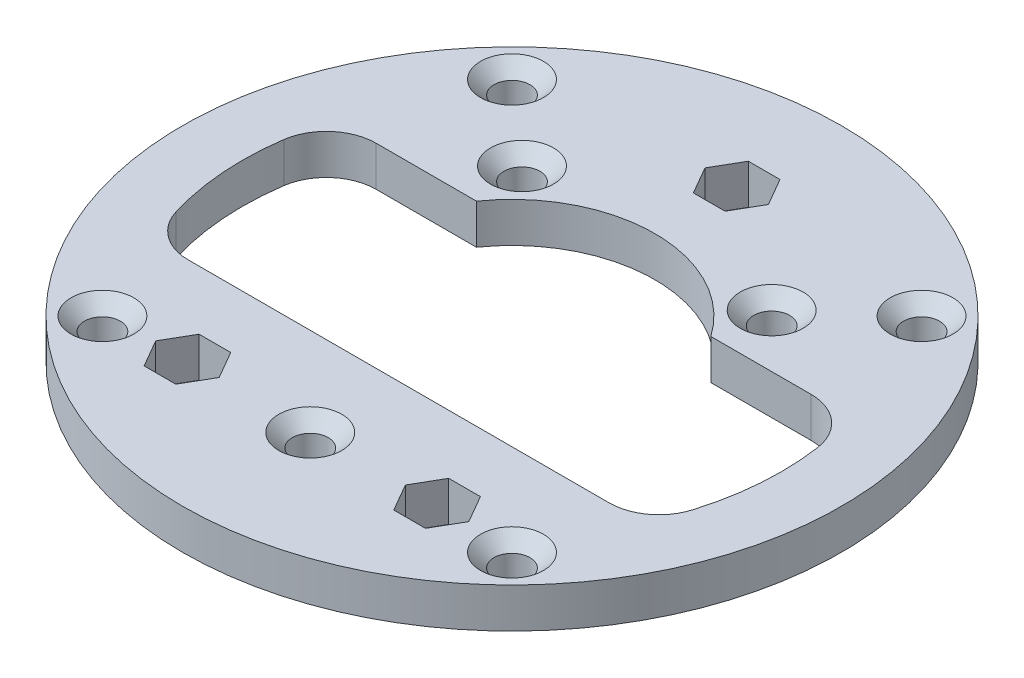
from build123d import *

# Parameters (mm, degrees)
SKETCH1_R                                       = 33
SKETCH1_R_2                                     = 27
BOSS_EXTRUDE1_DEPTH                             = 4
SKETCH2_R                                       = 1.5
SALIENTE_EXTRUIR1_DEPTH                         = 4
CORTAR_EXTRUIR1_REACH                           = 6
CROQUIS1_R                                      = 1.75
CSK_FOR_M3_FLAT_HEAD_MACHINE_SCREW1_D           = 3.6
CSK_FOR_M3_FLAT_HEAD_MACHINE_SCREW1_CSINK_D     = 6.3
CSK_FOR_M3_FLAT_HEAD_MACHINE_SCREW1_CSINK_ANGLE = 90
CSK_FOR_M3_FLAT_HEAD_MACHINE_SCREW2_D           = 3.6
CSK_FOR_M3_FLAT_HEAD_MACHINE_SCREW2_CSINK_D     = 6.3
CSK_FOR_M3_FLAT_HEAD_MACHINE_SCREW2_CSINK_ANGLE = 90
FILLET1_R                                       = 5


with BuildPart() as part:
    # Sketch1 → Boss-Extrude1 (new body)
    with BuildSketch(Plane(origin=(0, 0, 0), x_dir=(1, 0, 0), z_dir=(0, 1, 0))):
        Circle(SKETCH1_R)
        Circle(SKETCH1_R_2, mode=Mode.SUBTRACT)
    extrude(amount=BOSS_EXTRUDE1_DEPTH)

    # Sketch2 → Saliente-Extruir1 (add)
    with BuildSketch(Plane(origin=(0, 4, 0), x_dir=(1, 0, 0), z_dir=(0, 1, 0))):
        with BuildLine():
            Line((-24.5, -11.346805718), (24.5, -11.346805718))
            ThreePointArc((24.5, -11.346805718), (0, -27), (-24.5, -11.346805718))
        make_face()
        with Locations((0, -20.2)):
            Circle(SKETCH2_R, mode=Mode.SUBTRACT)
        with BuildLine():
            Line((-25.7325, 8.175478197), (-11.7325, 8.175478197))
            ThreePointArc((-11.7325, 8.175478197), (0, 14.3), (11.7325, 8.175478197))
            Line((11.7325, 8.175478197), (25.7325, 8.175478197))
            ThreePointArc((25.7325, 8.175478197), (0, 27), (-25.7325, 8.175478197))
        make_face()
        with Locations((-12.5, 13.5)):
            Circle(SKETCH2_R, mode=Mode.SUBTRACT)
        with Locations((12.5, 13.5)):
            Circle(SKETCH2_R, mode=Mode.SUBTRACT)
    extrude(amount=-SALIENTE_EXTRUIR1_DEPTH)

    # Croquis1 → Cortar-Extruir1 (cut, up to next)
    with BuildSketch(Plane(origin=(0, 4, 0), x_dir=(1, 0, 0), z_dir=(0, 1, 0)), mode=Mode.PRIVATE) as cortar_extruir1_sk1:
        with Locations((-20.506096654, 20.506096654)):
            Circle(CROQUIS1_R)
    cortar_extruir1_tool1 = extrude(cortar_extruir1_sk1.sketch, amount=-CORTAR_EXTRUIR1_REACH, mode=Mode.PRIVATE) & part.part
    add(cortar_extruir1_tool1.solids().sort_by_distance((-20.506097, 4, -20.506097))[0], mode=Mode.SUBTRACT)
    # Croquis1 → Cortar-Extruir1 (cut, up to next)
    with BuildSketch(Plane(origin=(0, 4, 0), x_dir=(1, 0, 0), z_dir=(0, 1, 0)), mode=Mode.PRIVATE) as cortar_extruir1_sk2:
        with Locations((20.506096654, 20.506096654)):
            Circle(CROQUIS1_R)
    cortar_extruir1_tool2 = extrude(cortar_extruir1_sk2.sketch, amount=-CORTAR_EXTRUIR1_REACH, mode=Mode.PRIVATE) & part.part
    add(cortar_extruir1_tool2.solids().sort_by_distance((20.506097, 4, -20.506097))[0], mode=Mode.SUBTRACT)
    # Croquis1 → Cortar-Extruir1 (cut, up to next)
    with BuildSketch(Plane(origin=(0, 4, 0), x_dir=(1, 0, 0), z_dir=(0, 1, 0)), mode=Mode.PRIVATE) as cortar_extruir1_sk3:
        with Locations((-20.506096654, -20.506096654)):
            Circle(CROQUIS1_R)
    cortar_extruir1_tool3 = extrude(cortar_extruir1_sk3.sketch, amount=-CORTAR_EXTRUIR1_REACH, mode=Mode.PRIVATE) & part.part
    add(cortar_extruir1_tool3.solids().sort_by_distance((-20.506097, 4, 20.506097))[0], mode=Mode.SUBTRACT)
    # Croquis1 → Cortar-Extruir1 (cut, up to next)
    with BuildSketch(Plane(origin=(0, 4, 0), x_dir=(1, 0, 0), z_dir=(0, 1, 0)), mode=Mode.PRIVATE) as cortar_extruir1_sk4:
        with Locations((20.506096654, -20.506096654)):
            Circle(CROQUIS1_R)
    cortar_extruir1_tool4 = extrude(cortar_extruir1_sk4.sketch, amount=-CORTAR_EXTRUIR1_REACH, mode=Mode.PRIVATE) & part.part
    add(cortar_extruir1_tool4.solids().sort_by_distance((20.506097, 4, 20.506097))[0], mode=Mode.SUBTRACT)
    # Croquis1 → Cortar-Extruir1 (cut, up to next)
    with BuildSketch(Plane(origin=(0, 4, 0), x_dir=(1, 0, 0), z_dir=(0, 1, 0)), mode=Mode.PRIVATE) as cortar_extruir1_sk5:
        Polygon((-9.324573519, -20), (-10.91228676, -17.25), (-14.08771324, -17.25), (-15.675426481, -20), (-14.08771324, -22.75), (-10.91228676, -22.75), align=None)
    cortar_extruir1_tool5 = extrude(cortar_extruir1_sk5.sketch, amount=-CORTAR_EXTRUIR1_REACH, mode=Mode.PRIVATE) & part.part
    add(cortar_extruir1_tool5.solids().sort_by_distance((-12.5, 4, 20))[0], mode=Mode.SUBTRACT)
    # Croquis1 → Cortar-Extruir1 (cut, up to next)
    with BuildSketch(Plane(origin=(0, 4, 0), x_dir=(1, 0, 0), z_dir=(0, 1, 0)), mode=Mode.PRIVATE) as cortar_extruir1_sk6:
        Polygon((15.675426481, -20), (14.08771324, -17.25), (10.91228676, -17.25), (9.324573519, -20), (10.91228676, -22.75), (14.08771324, -22.75), align=None)
    cortar_extruir1_tool6 = extrude(cortar_extruir1_sk6.sketch, amount=-CORTAR_EXTRUIR1_REACH, mode=Mode.PRIVATE) & part.part
    add(cortar_extruir1_tool6.solids().sort_by_distance((12.5, 4, 20))[0], mode=Mode.SUBTRACT)
    # Croquis1 → Cortar-Extruir1 (cut, up to next)
    with BuildSketch(Plane(origin=(0, 4, 0), x_dir=(1, 0, 0), z_dir=(0, 1, 0)), mode=Mode.PRIVATE) as cortar_extruir1_sk7:
        Polygon((3.175426481, 22.5), (1.58771324, 25.25), (-1.58771324, 25.25), (-3.175426481, 22.5), (-1.58771324, 19.75), (1.58771324, 19.75), align=None)
    cortar_extruir1_tool7 = extrude(cortar_extruir1_sk7.sketch, amount=-CORTAR_EXTRUIR1_REACH, mode=Mode.PRIVATE) & part.part
    add(cortar_extruir1_tool7.solids().sort_by_distance((0, 4, -22.5))[0], mode=Mode.SUBTRACT)

    # CSK for M3 Flat Head Machine Screw1 (through all)
    with Locations(Plane(origin=(0, 4, 0), x_dir=(1, 0, 0), z_dir=(0, 1, 0))):
        with Locations((-20.506096654, 20.506096654), (20.506096654, 20.506096654), (20.506096654, -20.506096654), (-20.506096654, -20.506096654)):
            CounterSinkHole(CSK_FOR_M3_FLAT_HEAD_MACHINE_SCREW1_D / 2, CSK_FOR_M3_FLAT_HEAD_MACHINE_SCREW1_CSINK_D / 2, counter_sink_angle=CSK_FOR_M3_FLAT_HEAD_MACHINE_SCREW1_CSINK_ANGLE)

    # CSK for M3 Flat Head Machine Screw2 (through all)
    with Locations(Plane(origin=(0, 4, 0), x_dir=(1, 0, 0), z_dir=(0, 1, 0))):
        with Locations((-12.5, 13.5), (12.5, 13.5), (0, -20.2)):
            CounterSinkHole(CSK_FOR_M3_FLAT_HEAD_MACHINE_SCREW2_D / 2, CSK_FOR_M3_FLAT_HEAD_MACHINE_SCREW2_CSINK_D / 2, counter_sink_angle=CSK_FOR_M3_FLAT_HEAD_MACHINE_SCREW2_CSINK_ANGLE)

    # Fillet1
    fillet1_edges = [part.edges().sort_by_distance(p)[0] for p in [
        (-25.7325, 2, -8.175478197),
        (25.7325, 2, -8.175478197),
        (24.5, 2, 11.346805718),
        (-24.5, 2, 11.346805718),
    ]]
    fillet(fillet1_edges, radius=FILLET1_R)


solid = part.part
